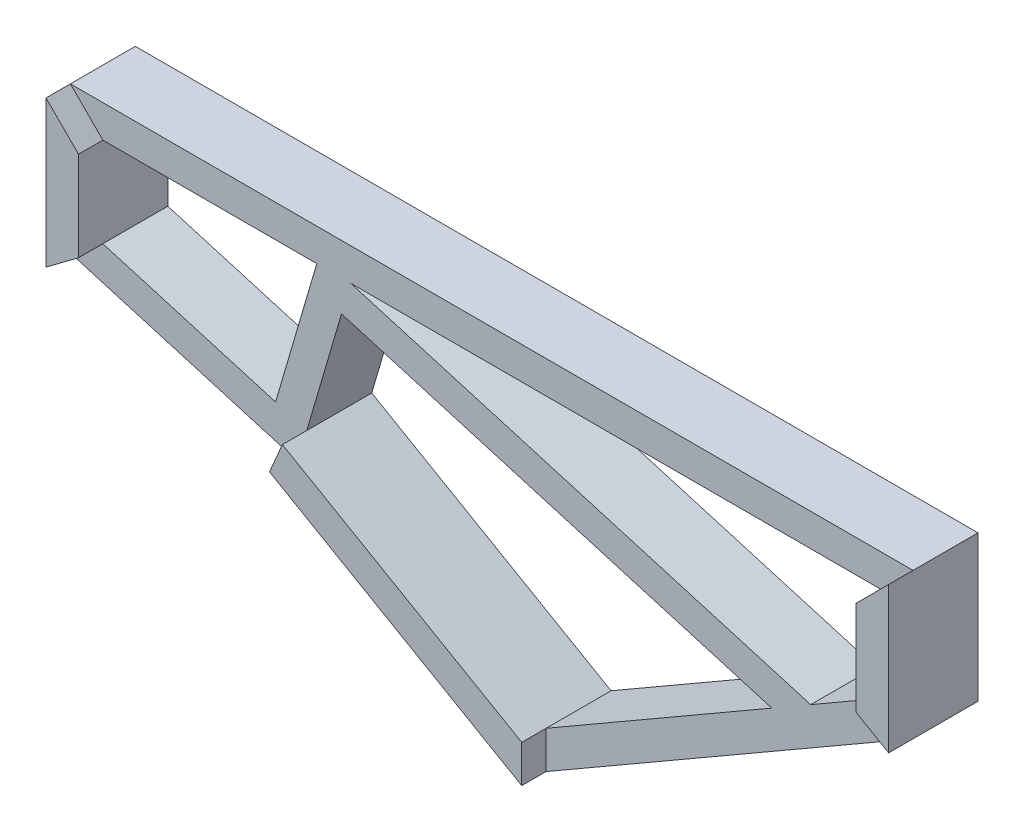
from build123d import *

# Parameters (mm, degrees)
SKETCH_6_W      = 80
SKETCH_6_H      = 40
SKETCH_6_W_2    = 76
SKETCH_6_H_2    = 36
SKETCH_14_W     = 40
SKETCH_14_H     = 80
EXTRUDE_1_DEPTH = 194
SKETCH_15_W     = 80
SKETCH_15_H     = 40
EXTRUDE_2_DEPTH = 595
EXTRUDE_3_DEPTH = 30
EXTRUDE_4_DEPTH = 30
EXTRUDE_5_DEPTH = 30


with BuildPart() as part:
    # По траектории13: sweep along a curve in space
    with BuildLine() as sweep_13_path:
        Line((0, 0, 0), (1000, 0, 0))
        Line((1000, 0, 0), (1000, -150, 0))
        Line((1000, -150, 0), (566.987298108, -400, 0))
        Line((566.987298108, -400, 0), (263.878406783, -225, 0))
        Line((263.878406783, -225, 0), (0, -147.584326952, 0))
        Line((0, -147.584326952, 0), (0, 0, 0))
    # Эскиз6 → По траектории13 (sweep)
    with BuildSketch(Plane(origin=(0, 0, 0), x_dir=(0, 0, -1), z_dir=(1, 0, 0))):
        with Locations((-0.551773823, -1.216505436)):
            Rectangle(SKETCH_6_W, SKETCH_6_H)
        with Locations((-0.551773823, -1.216505436)):
            Rectangle(SKETCH_6_W_2, SKETCH_6_H_2, mode=Mode.SUBTRACT)
    sweep(path=sweep_13_path.line, transition=Transition.RIGHT)

    # Эскиз14 → Бобышка-Вытянуть1 (add)
    with BuildSketch(Plane(origin=(-33.89376203, -115.529989888, 0), x_dir=(0.9595578428480989, -0.2815115383580276, 0), z_dir=(0.2815115383580276, 0.9595578428480989, 0))):
        with Locations((299.085913187, -0.551773823)):
            Rectangle(SKETCH_14_W, SKETCH_14_H)
    extrude(amount=EXTRUDE_1_DEPTH)

    # Эскиз15 → Бобышка-Вытянуть2 (add)
    with BuildSketch(Plane(origin=(306.181390541, -89.82636629, 0), x_dir=(0, 0, -1), z_dir=(0.9595578428480989, -0.28151153835802767, 0))):
        with Locations((-0.551773823, 51.50143726)):
            Rectangle(SKETCH_15_W, SKETCH_15_H)
    extrude(amount=EXTRUDE_2_DEPTH)

    # Эскиз17 → Бобышка-Вытянуть3 (add)
    with BuildSketch(Plane.XY.offset(40.551773823)):
        Polygon((-18.783494564, 18.783494564), (21.216505436, -21.216505436), (21.216505436, -131.698036755), (-18.783494564, -161.648850746), align=None)
    extrude(amount=EXTRUDE_3_DEPTH)

    # Эскиз18 → Бобышка-Вытянуть4 (add)
    with BuildSketch(Plane.XY.offset(40.551773823)):
        Polygon((272.28762851, -205.356356178), (256.433515773, -242.391001456), (566.987298108, -421.689311285), (566.987298108, -375.50128975), align=None)
    extrude(amount=EXTRUDE_4_DEPTH)

    # Эскиз19 → Бобышка-Вытянуть5 (add)
    with BuildSketch(Plane.XY.offset(40.551773823)):
        Polygon((1018.783494564, 18.783494564), (978.783494564, -21.216505436), (978.783494564, -137.750644875), (1018.783494564, -160.844655643), align=None)
    extrude(amount=EXTRUDE_5_DEPTH)


solid = part.part
